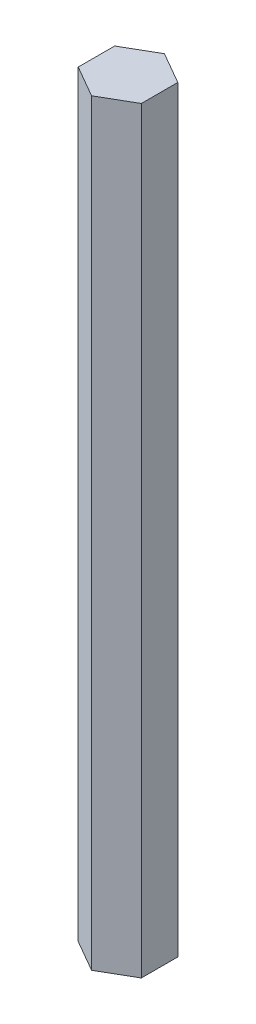
from build123d import *

# Parameters (mm, degrees)
BOSS_EXTRUDE1_DEPTH = 120
SKETCH2_R           = 3
CUT_EXTRUDE2_DEPTH  = 5


with BuildPart() as part:
    # Sketch1 → Boss-Extrude1 (new body)
    with BuildSketch(Plane(origin=(0, 0, 0), x_dir=(1, 0, 0), z_dir=(0, 1, 0))):
        Polygon((0, 5.773502692), (-5, 2.886751346), (-5, -2.886751346), (0, -5.773502692), (5, -2.886751346), (5, 2.886751346), align=None)
    extrude(amount=BOSS_EXTRUDE1_DEPTH)

    # Sketch2 → Cut-Extrude2 (cut)
    with BuildSketch(Plane.XZ):
        Circle(SKETCH2_R)
    extrude(amount=-CUT_EXTRUDE2_DEPTH, mode=Mode.SUBTRACT)


solid = part.part
